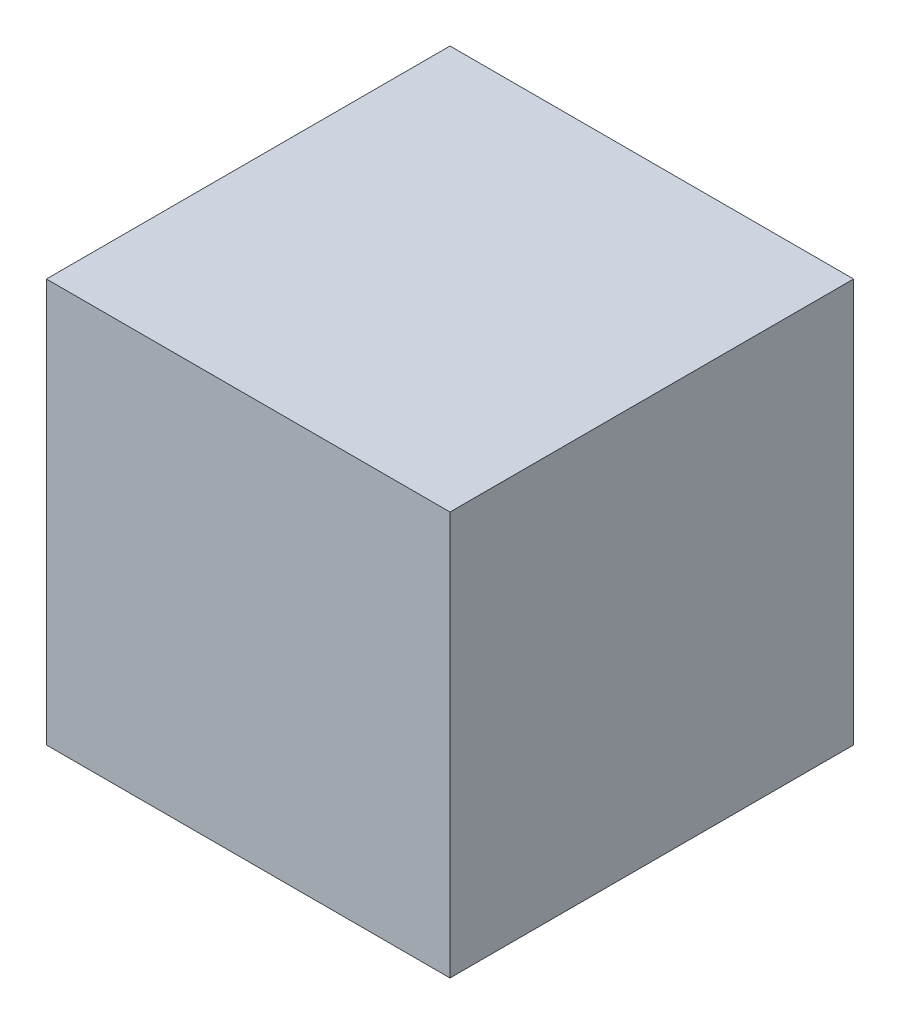
from build123d import *

# Parameters (mm, degrees)
SKETCH1_W           = 130
SKETCH1_H           = 130
BOSS_EXTRUDE1_DEPTH = 130


with BuildPart() as part:
    # Sketch1 → Boss-Extrude1 (new body)
    with BuildSketch(Plane(origin=(0, 0, 0), x_dir=(1, 0, 0), z_dir=(0, 1, 0))):
        with Locations((65, 65)):
            Rectangle(SKETCH1_W, SKETCH1_H)
    extrude(amount=BOSS_EXTRUDE1_DEPTH)


solid = part.part
